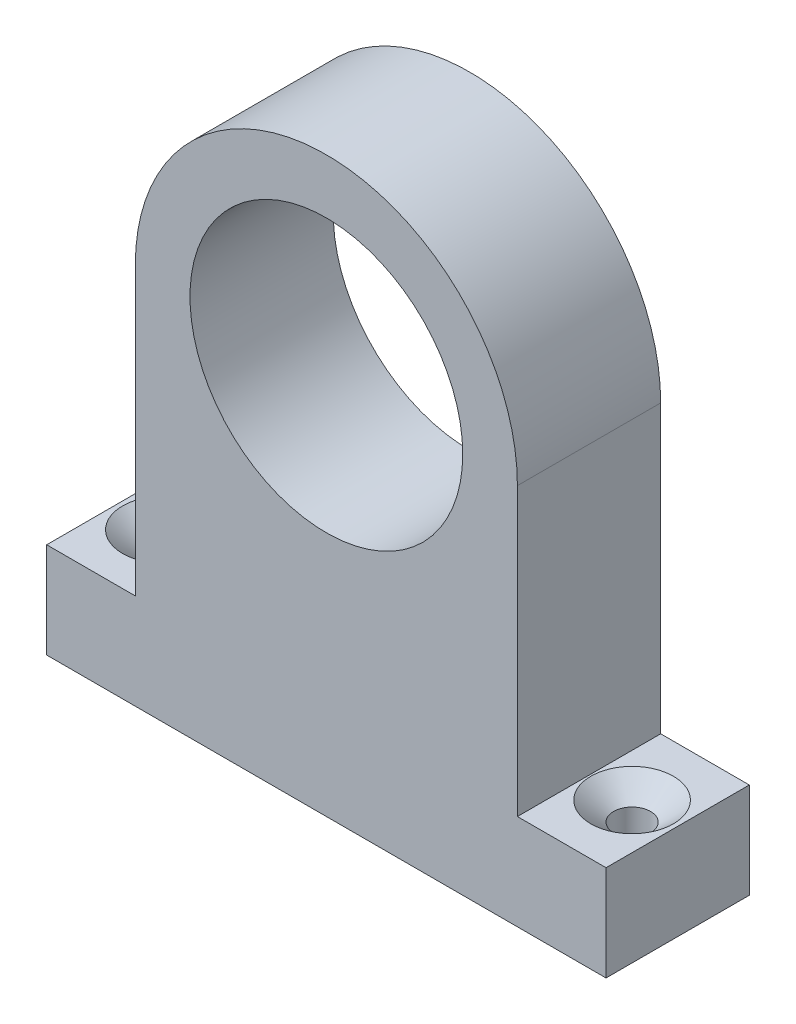
from build123d import *

# Parameters (mm, degrees)
SKETCH1_W                                         = 74.3632
SKETCH1_H                                         = 19.05
BOSS_EXTRUDE2_DEPTH                               = 76.2
SKETCH2_R                                         = 18.1316
CUT_EXTRUDE1_DEPTH                                = 20.05
CSK_FOR_8_FLAT_HEAD_MACHINE_SCREW_100_D           = 4.9149
CSK_FOR_8_FLAT_HEAD_MACHINE_SCREW_100_CSINK_D     = 10.9728
CSK_FOR_8_FLAT_HEAD_MACHINE_SCREW_100_CSINK_ANGLE = 100


with BuildPart() as part:
    # Sketch1 → Boss-Extrude2 (new body)
    with BuildSketch(Plane(origin=(0, 19.05, 0), x_dir=(1, 0, 0), z_dir=(0, 1, 0))):
        with Locations((0, -87.9856)):
            Rectangle(SKETCH1_W, SKETCH1_H)
    extrude(amount=BOSS_EXTRUDE2_DEPTH)

    # Sketch2 → Cut-Extrude1 (cut, through all)
    with BuildSketch(Plane.XY.offset(97.5106)):
        with BuildLine():
            Line((-37.1816, 95.25), (-37.1816, 31.75))
            Line((-37.1816, 31.75), (-25.4, 31.75))
            Line((-25.4, 31.75), (-25.4, 69.85))
            ThreePointArc((-25.4, 69.85), (-17.960512267, 87.810512217), (-7.1e-08, 95.25))
            Line((-7.1e-08, 95.25), (-37.1816, 95.25))
        make_face()
        with BuildLine():
            Line((25.4, 69.85), (25.4, 31.75))
            Line((25.4, 31.75), (37.1816, 31.75))
            Line((37.1816, 31.75), (37.1816, 95.25))
            Line((37.1816, 95.25), (-7.1e-08, 95.25))
            ThreePointArc((-7.1e-08, 95.25), (17.960512217, 87.810512267), (25.4, 69.85))
        make_face()
        with Locations((0, 69.85)):
            Circle(SKETCH2_R)
    extrude(amount=-CUT_EXTRUDE1_DEPTH, mode=Mode.SUBTRACT)

    # CSK for #8 Flat Head Machine Screw (100)1 (through all)
    with Locations(Plane(origin=(0, 31.75, 0), x_dir=(1, 0, 0), z_dir=(0, 1, 0))):
        with Locations((-31.125, -87.9856), (31.125, -87.9856)):
            CounterSinkHole(CSK_FOR_8_FLAT_HEAD_MACHINE_SCREW_100_D / 2, CSK_FOR_8_FLAT_HEAD_MACHINE_SCREW_100_CSINK_D / 2, counter_sink_angle=CSK_FOR_8_FLAT_HEAD_MACHINE_SCREW_100_CSINK_ANGLE)


solid = part.part
